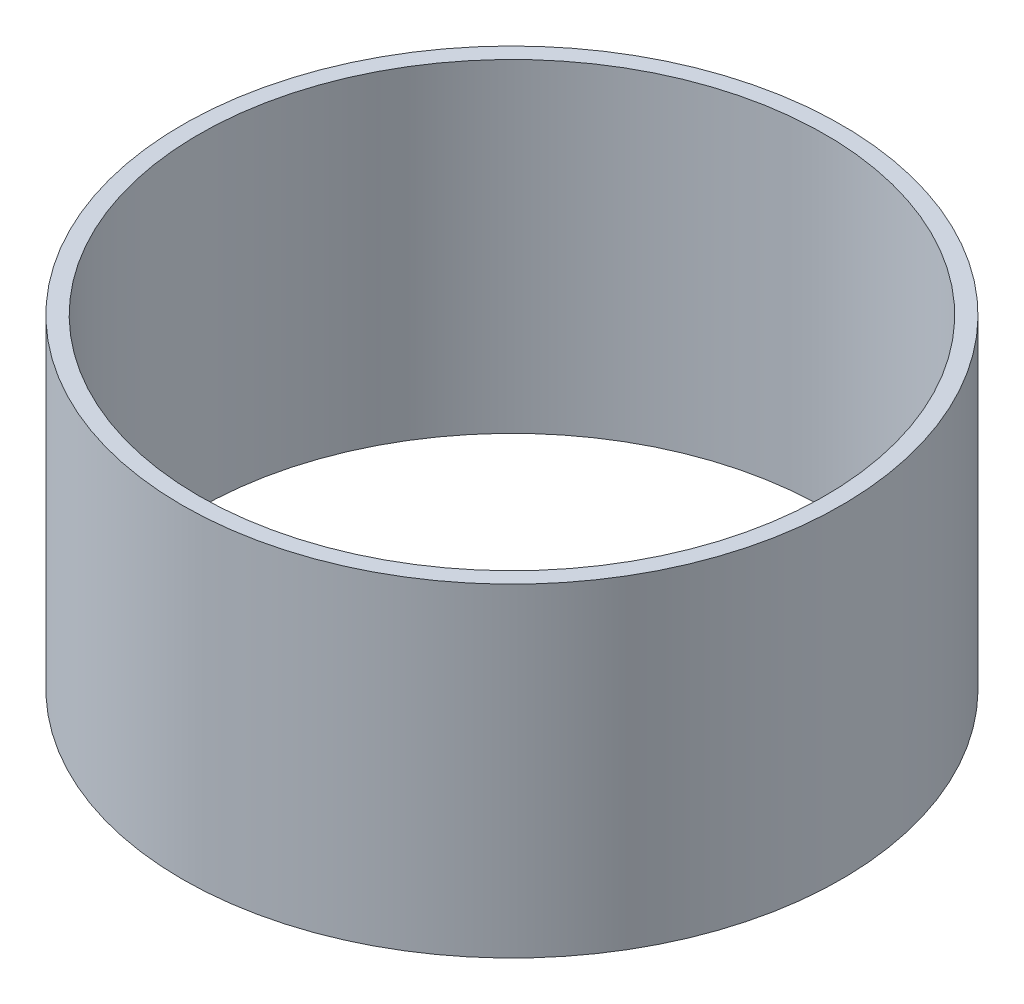
from build123d import *

# Parameters (mm, degrees)
SKETCH_1_R      = 40
SKETCH_1_R_2    = 38
EXTRUDE_1_DEPTH = 39.3


with BuildPart() as part:
    # 草图1 → 凸台-拉伸1 (new body)
    with BuildSketch(Plane(origin=(0, 0, 0), x_dir=(1, 0, 0), z_dir=(0, 1, 0))):
        Circle(SKETCH_1_R)
        Circle(SKETCH_1_R_2, mode=Mode.SUBTRACT)
    extrude(amount=EXTRUDE_1_DEPTH)


solid = part.part
